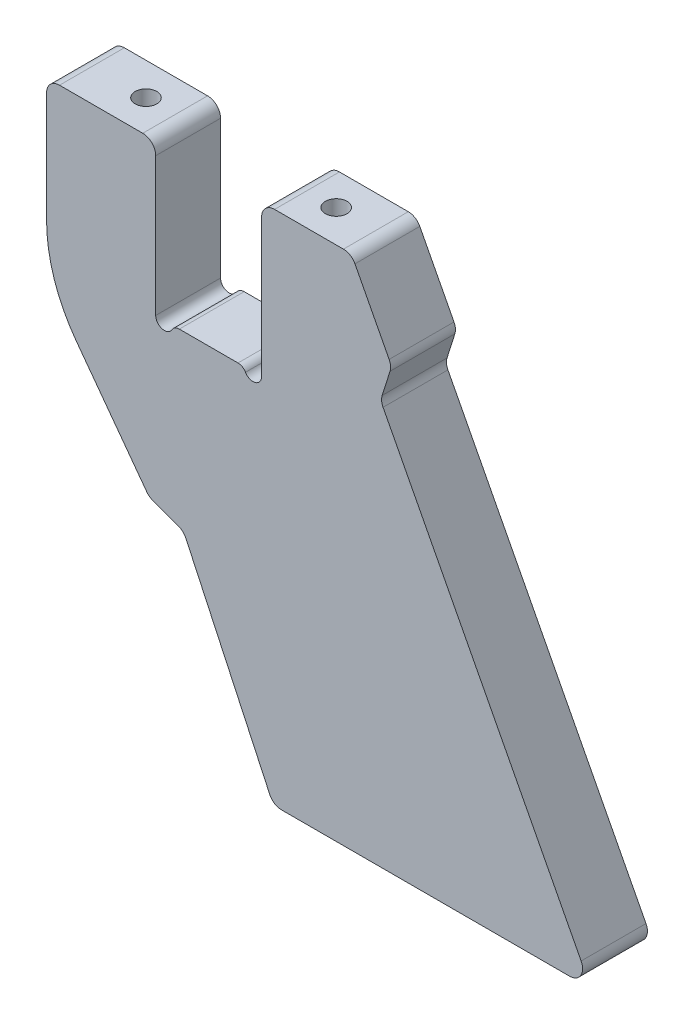
from build123d import *

# Parameters (mm, degrees)
EXTRUDE1_DEPTH = 15
HOLE1_D        = 5
HOLE1_DEPTH    = 15
HOLE1_TIP      = 1.502151548


with BuildPart() as part:
    # Sketch1 → Extrude1 (new body)
    with BuildSketch(Plane.XY):
        with BuildLine():
            Line((-6.785898385, 0), (6.785898385, 0))
            ThreePointArc((6.785898385, 0), (7.785898385, -0.267949192), (8.517949192, -1))
            ThreePointArc((8.517949192, -1), (10.76763809, -1.931851653), (12.25, 0))
            Line((12.25, 0), (12.25, 32))
            ThreePointArc((12.25, 32), (13.128679656, 34.121320344), (15.25, 35))
            Line((15.25, 35), (31.179555311, 35))
            ThreePointArc((31.179555311, 35), (32.735875086, 34.564735612), (33.840587811, 33.38524584))
            Line((33.840587811, 33.38524584), (41.748237339, 18.19479243))
            ThreePointArc((41.748237339, 18.19479243), (42.075788934, 17.071013818), (41.948355691, 15.907429191))
            Line((41.948355691, 15.907429191), (40.144120894, 10.185127487))
            ThreePointArc((40.144120894, 10.185127487), (40.016687652, 9.02154286), (40.344239247, 7.897764249))
            Line((40.344239247, 7.897764249), (86.160656367, -80.11475416))
            ThreePointArc((86.160656367, -80.11475416), (86.064359479, -83.056319774), (83.499623867, -84.5))
            Line((83.499623867, -84.5), (16.854681642, -84.5))
            ThreePointArc((16.854681642, -84.5), (15.242782817, -84.030174337), (14.135758281, -82.767854785))
            Line((14.135758281, -82.767854785), (-5.282057281, -41.126214931))
            ThreePointArc((-5.282057281, -41.126214931), (-5.974210019, -40.182237706), (-6.974920212, -39.574991854))
            Line((-6.974920212, -39.574991854), (-12.931340914, -37.407032016))
            ThreePointArc((-12.931340914, -37.407032016), (-13.701027508, -36.991138005), (-14.317998731, -36.370870489))
            Line((-14.317998731, -36.370870489), (-30.648379548, -14.271904325))
            ThreePointArc((-30.648379548, -14.271904325), (-35.74299388, -4.421252914), (-37.5, 6.52878626))
            Line((-37.5, 6.52878626), (-37.5, 32))
            ThreePointArc((-37.5, 32), (-36.621320344, 34.121320344), (-34.5, 35))
            Line((-34.5, 35), (-15.25, 35))
            ThreePointArc((-15.25, 35), (-13.128679656, 34.121320344), (-12.25, 32))
            Line((-12.25, 32), (-12.25, 0))
            ThreePointArc((-12.25, 0), (-10.76763809, -1.931851653), (-8.517949192, -1))
            ThreePointArc((-8.517949192, -1), (-7.785898385, -0.267949192), (-6.785898385, 0))
        make_face()
    extrude(amount=EXTRUDE1_DEPTH)

    # Hole1
    with Locations(Plane(origin=(0, 35, 0), x_dir=(-1, 0, 0), z_dir=(0, 1, 0))):
        with Locations((-22, 7.5), (22, 7.5)):
            Hole(HOLE1_D / 2, depth=HOLE1_DEPTH)
            with Locations((0, 0, -(HOLE1_DEPTH + HOLE1_TIP / 2))):  # 118° drill point
                Cone(0, HOLE1_D / 2, HOLE1_TIP, mode=Mode.SUBTRACT)


solid = part.part
